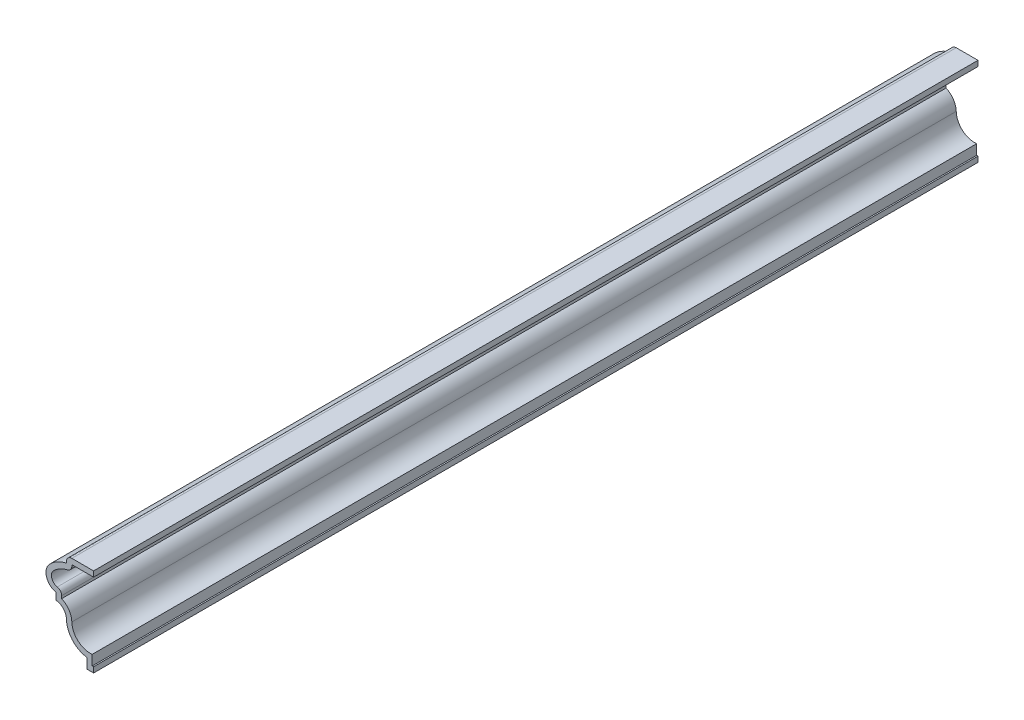
from build123d import *

# Parameters (mm, degrees)
EXTRUDE_THIN1_DEPTH = 206.375
FILLET1_R           = 1.27


with BuildPart() as part:
    # Sketch1 → Extrude-Thin1 (new body)
    with BuildSketch(Plane.XY):
        with BuildLine():
            Line((0, 0), (-1.5875, 0))
            Line((-1.5875, 0), (-1.5875, 2.38125))
            ThreePointArc((-1.5875, 2.38125), (-4.95373921, 4.191798454), (-6.35, 7.749902995))
            ThreePointArc((-6.35, 7.749902995), (-7.0533091, 9.486054835), (-8.73125, 10.31875))
            Line((-8.73125, 10.31875), (-8.73125, 11.90625))
            ThreePointArc((-8.73125, 11.90625), (-10.983204711, 13.93861616), (-10.254760064, 16.883303007))
            ThreePointArc((-10.254760064, 16.883303007), (-8.456232552, 18.243920166), (-6.35, 19.05))
            Line((-6.35, 19.05), (-6.35, 20.6375))
            Line((-6.35, 20.6375), (0, 20.6375))
            Line((0, 20.6375), (0, 19.3675))
            Line((0, 19.3675), (-5.08, 19.3675))
            Line((-5.08, 19.3675), (-5.08, 17.961479369))
            ThreePointArc((-5.08, 17.961479369), (-7.394462244, 17.359516713), (-9.353746016, 15.988275809))
            ThreePointArc((-9.353746016, 15.988275809), (-9.540424793, 13.84093001), (-7.46125, 13.272621004))
            Line((-7.46125, 13.272621004), (-7.46125, 11.290352642))
            ThreePointArc((-7.46125, 11.290352642), (-5.752972349, 9.885293584), (-5.080314797, 7.778178184))
            ThreePointArc((-5.080314797, 7.778178184), (-3.615692697, 4.649806034), (-0.3175, 3.623280274))
            Line((-0.3175, 3.623280274), (-0.3175, 1.27))
            Line((-0.3175, 1.27), (0, 1.27))
            Line((0, 1.27), (0, 0))
        make_face()
    extrude(amount=-EXTRUDE_THIN1_DEPTH)

    # Fillet1
    fillet1_edges = [part.edges().sort_by_distance(p)[0] for p in [
        (-5.08, 17.961479369, -103.1875),
        (-7.46125, 13.272621004, -103.1875),
        (-6.35, 20.6375, -103.1875),
    ]]
    fillet(fillet1_edges, radius=FILLET1_R)


solid = part.part
